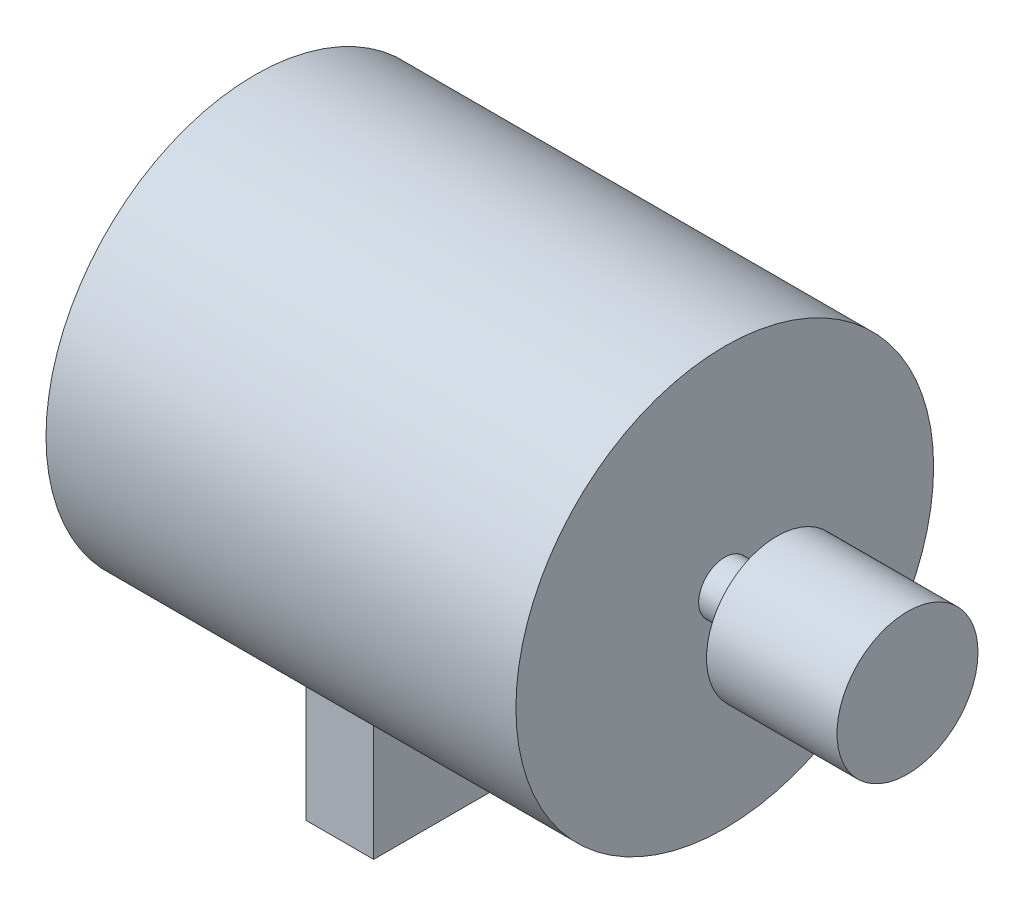
from build123d import *

# Parameters (mm, degrees)
SKETCH4_W                       = 9
SKETCH4_H                       = 4
BOSS_EXTRUDE1_REACH             = 12.012
BOSS_EXTRUDE1_END_RADIUS        = 4
SKETCH5_W                       = 1.3
SKETCH5_H                       = 5.75
BOSS_EXTRUDE1_DIRECTION_2_DEPTH = 1
SKETCH6_R                       = 0.5
BOSS_EXTRUDE2_DEPTH             = 3.5
SKETCH7_R                       = 1.35
BOSS_EXTRUDE3_DEPTH             = 2.5


with BuildPart() as part:
    # Sketch4 → Revolve3 (revolve)
    with BuildSketch(Plane.XY):
        with Locations((0, 2)):
            Rectangle(SKETCH4_W, SKETCH4_H)
    revolve(axis=Axis((-4.5, 4, 0), (1, 0, 0)))

    # Boss-Extrude1: up to this cylinder (the profile starts outside it)
    boss_extrude1_end = Plane(origin=(0, 4, 0), z_dir=(-1, 0, 0)) * Cylinder(BOSS_EXTRUDE1_END_RADIUS, 33.024, mode=Mode.PRIVATE)
    # Sketch5 → Boss-Extrude1 (add, up to the surface)
    with BuildSketch(Plane(origin=(0, 0, 0), x_dir=(1, 0, 0), z_dir=(0, 1, 0)), mode=Mode.PRIVATE) as boss_extrude1_sk1:
        Rectangle(SKETCH5_W, SKETCH5_H)
    boss_extrude1_tool1 = extrude(boss_extrude1_sk1.sketch, amount=BOSS_EXTRUDE1_REACH, mode=Mode.PRIVATE) - boss_extrude1_end
    add(boss_extrude1_tool1.solids().sort_by_distance((0, 0, 0))[0])
    add(boss_extrude1_tool1.solids().sort_by_distance((0, 0, 0))[1])

    # Sketch5 → Boss-Extrude1 direction 2 (add)
    with BuildSketch(Plane(origin=(0, 0, 0), x_dir=(1, 0, 0), z_dir=(0, 1, 0))):
        Rectangle(SKETCH5_W, SKETCH5_H)
    extrude(amount=-BOSS_EXTRUDE1_DIRECTION_2_DEPTH)

    # Sketch6 → Boss-Extrude2 (add)
    with BuildSketch(Plane(origin=(4.5, 0, 0), x_dir=(0, 0, -1), z_dir=(1, 0, 0))):
        with Locations((0, 4)):
            Circle(SKETCH6_R)
    extrude(amount=BOSS_EXTRUDE2_DEPTH)

    # Sketch7 → Boss-Extrude3 (add)
    with BuildSketch(Plane(origin=(8, 0, 0), x_dir=(0, 0, -1), z_dir=(1, 0, 0))):
        with Locations((0, 4)):
            Circle(SKETCH7_R)
    extrude(amount=-BOSS_EXTRUDE3_DEPTH)


solid = part.part
